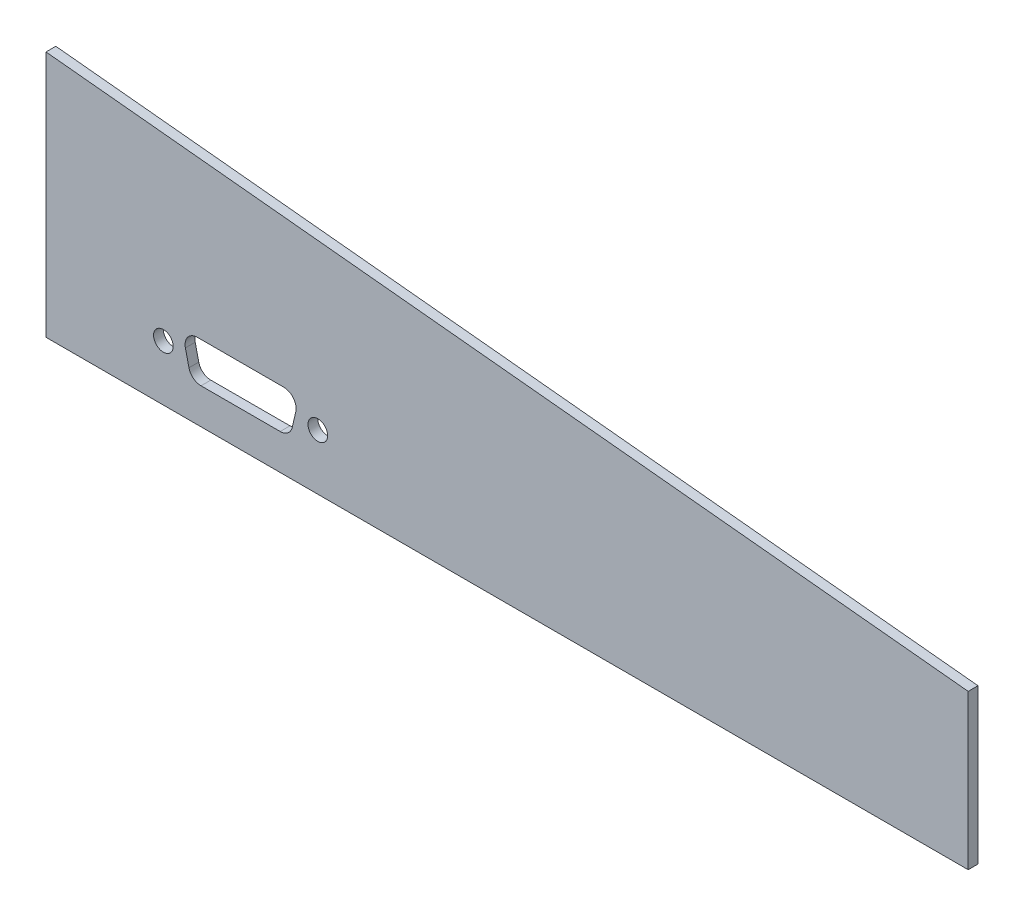
from build123d import *

# Parameters (mm, degrees)
ESQUISSE1_R        = 1.59
BOSS_EXTRU_1_DEPTH = 1.5875
CONG_1_R           = 2


with BuildPart() as part:
    # Esquisse1 → Boss.-Extru.1 (new body)
    with BuildSketch(Plane.XY):
        Polygon((-149.248115566, 40), (-149.248115566, 0), (0, 0), (0, 25), align=None)
        with Locations((-130.248115566, 9)):
            Circle(ESQUISSE1_R, mode=Mode.SUBTRACT)
        with Locations((-105.258115566, 9)):
            Circle(ESQUISSE1_R, mode=Mode.SUBTRACT)
        Polygon((-127.253115566, 12.25), (-108.253115566, 12.25), (-109.753115566, 5.75), (-125.753115566, 5.75), align=None, mode=Mode.SUBTRACT)
    extrude(amount=BOSS_EXTRU_1_DEPTH)

    # Congé1
    cong_1_edges = [part.edges().sort_by_distance(p)[0] for p in [
        (-127.253115566, 12.25, 0.79375),
        (-125.753115566, 5.75, 0.79375),
        (-109.753115566, 5.75, 0.79375),
        (-108.253115566, 12.25, 0.79375),
    ]]
    fillet(cong_1_edges, radius=CONG_1_R)


solid = part.part
